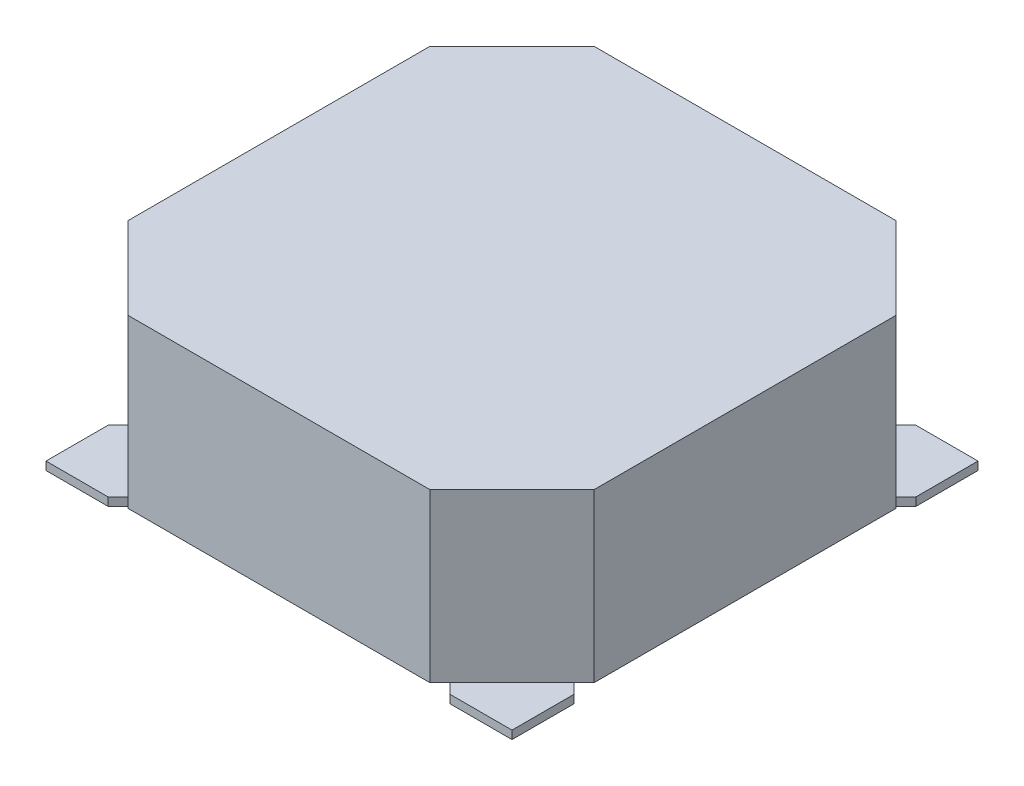
from build123d import *

# Parameters (mm, degrees)
SKETCH1_W           = 8.5
SKETCH1_H           = 8.5
BOSS_EXTRUDE1_DEPTH = 3.2
CUT_EXTRUDE1_DEPTH  = 3.05
CUT_EXTRUDE2_DEPTH  = 0.15


with BuildPart() as part:
    # Sketch1 → Boss-Extrude1 (new body)
    with BuildSketch(Plane(origin=(0, 0, 0), x_dir=(1, 0, 0), z_dir=(0, 1, 0))):
        with Locations((4.25, -4.25)):
            Rectangle(SKETCH1_W, SKETCH1_H)
    extrude(amount=BOSS_EXTRUDE1_DEPTH)

    # Sketch2 → Cut-Extrude1 (cut)
    with BuildSketch(Plane(origin=(0, 3.2, 0), x_dir=(1, 0, 0), z_dir=(0, 1, 0))):
        Polygon((1.5, -8.5), (0, -7), (0, -8.5), align=None)
        Polygon((0, -1.5), (1.5, 0), (0, 0), align=None)
        Polygon((8.5, 0), (7, 0), (8.5, -1.5), align=None)
        Polygon((8.5, -8.5), (8.5, -7), (7, -8.5), align=None)
    extrude(amount=-CUT_EXTRUDE1_DEPTH, mode=Mode.SUBTRACT)

    # Sketch3 → Cut-Extrude2 (cut)
    with BuildSketch(Plane.XZ):
        Polygon((8.5, 1.13137085), (7.969669914, 1.661700936), (6.838299064, 0.530330086), (7.36862915, 0), (1.13137085, 0), (1.661700936, 0.530330086), (0.530330086, 1.661700936), (0, 1.13137085), (0, 7.36862915), (0.530330086, 6.838299064), (1.661700936, 7.969669914), (1.13137085, 8.5), (7.36862915, 8.5), (6.838299064, 7.969669914), (7.969669914, 6.838299064), (8.5, 7.36862915), align=None)
    extrude(amount=-CUT_EXTRUDE2_DEPTH, mode=Mode.SUBTRACT)


solid = part.part
